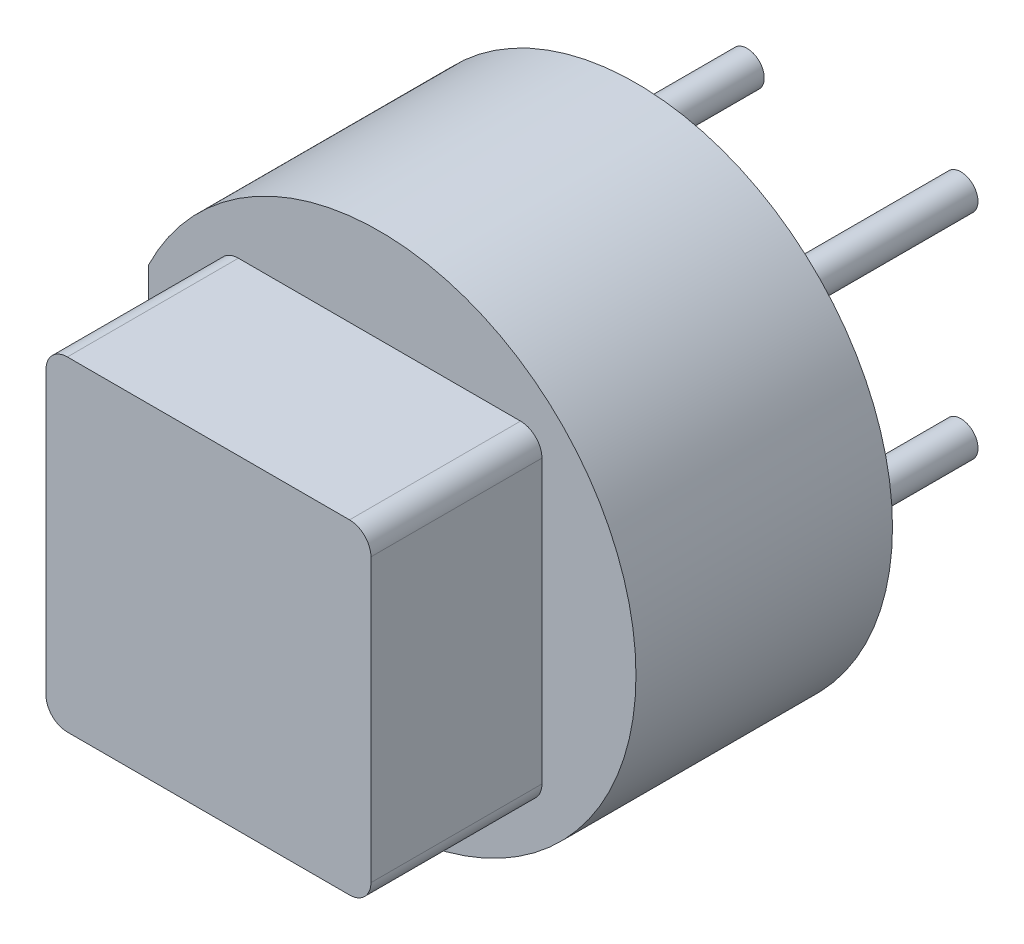
from build123d import *

# Parameters (mm, degrees)
BOSS_EXTRU_1_DEPTH      = 6
ESQUISSE2_W             = 7.6
ESQUISSE2_H             = 7.6
BOSS_EXTRU_2_DEPTH      = 4
ENL_V_MAT_EXTRU_1_DEPTH = 0.1
ESQUISSE4_R             = 1.5
ESQUISSE4_R_2           = 0.6
BOSS_EXTRU_4_DEPTH      = 1.2
ESQUISSE5_R             = 0.4
BOSS_EXTRU_5_DEPTH      = 5.2
CONG_1_R                = 0.5


with BuildPart() as part:
    # Esquisse1 → Boss.-Extru.1 (new body)
    with BuildSketch(Plane.XY):
        with BuildLine():
            Line((-5.4, 2.615339366), (-5.4, -2.615339366))
            ThreePointArc((-5.4, -2.615339366), (6, 0), (-5.4, 2.615339366))
        make_face()
    extrude(amount=BOSS_EXTRU_1_DEPTH)

    # Esquisse2 → Boss.-Extru.2 (add)
    with BuildSketch(Plane.XY.offset(6)):
        Rectangle(ESQUISSE2_W, ESQUISSE2_H)
    extrude(amount=BOSS_EXTRU_2_DEPTH)

    # Esquisse3 → Enlèv. mat.-Extru.1 (cut)
    with BuildSketch(Plane(origin=(0, 0, 0), x_dir=(-1, 0, 0), z_dir=(0, 0, -1))):
        with BuildLine():
            Line((4.8, -2.473863375), (4.8, 2.473863375))
            ThreePointArc((4.8, 2.473863375), (-5.4, 0), (4.8, -2.473863375))
        make_face()
    extrude(amount=-ENL_V_MAT_EXTRU_1_DEPTH, mode=Mode.SUBTRACT)

    # Esquisse4 → Boss.-Extru.4 (add)
    with BuildSketch(Plane(origin=(0, 0, 0.1), x_dir=(-1, 0, 0), z_dir=(0, 0, -1))):
        Circle(ESQUISSE4_R)
        with Locations((0, -4)):
            Circle(ESQUISSE4_R_2)
        with Locations((-4, 0)):
            Circle(ESQUISSE4_R_2)
        with Locations((0, 4)):
            Circle(ESQUISSE4_R_2)
        with Locations((4, 0)):
            Circle(ESQUISSE4_R_2)
    extrude(amount=BOSS_EXTRU_4_DEPTH)

    # Esquisse5 → Boss.-Extru.5 (add)
    with BuildSketch(Plane(origin=(0, 0, 0.1), x_dir=(-1, 0, 0), z_dir=(0, 0, -1))):
        with Locations((2.5, -2.5)):
            Circle(ESQUISSE5_R)
        with Locations((-2.5, -2.5)):
            Circle(ESQUISSE5_R)
        with Locations((-2.5, 2.5)):
            Circle(ESQUISSE5_R)
        with Locations((2.5, 2.5)):
            Circle(ESQUISSE5_R)
    extrude(amount=BOSS_EXTRU_5_DEPTH)

    # Congé1
    cong_1_edges = [part.edges().sort_by_distance(p)[0] for p in [
        (3.8, -3.8, 8),
        (3.8, 3.8, 8),
        (-3.8, 3.8, 8),
        (-3.8, -3.8, 8),
    ]]
    fillet(cong_1_edges, radius=CONG_1_R)


solid = part.part
